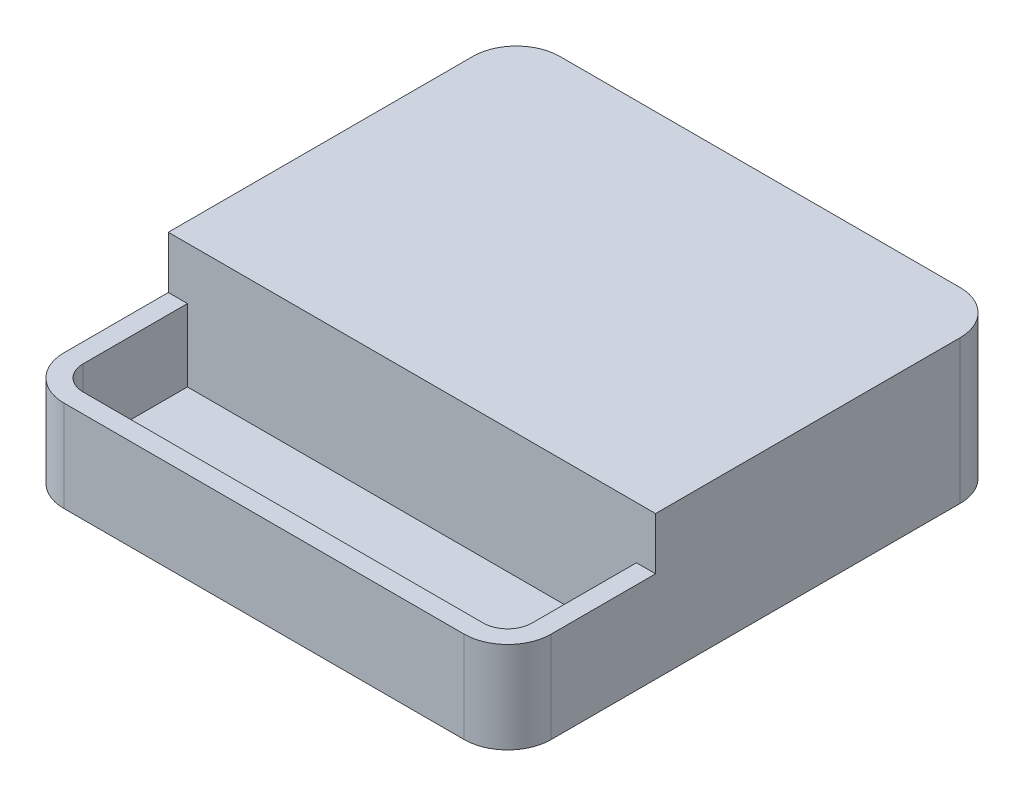
from build123d import *

# Parameters (mm, degrees)
EXTRUDE_1_DEPTH     = 16.5
SKETCH_2_W          = 56
SKETCH_2_H          = 17
CUT_EXTRUDE_1_DEPTH = 6
CUT_EXTRUDE_2_DEPTH = 8.3
SKETCH_4_R          = 7
SKETCH_4_R_2        = 0.5
EXTRUDE_2_DEPTH     = 1
SKETCH_5_R          = 4
EXTRUDE_3_DEPTH     = 4.5
SKETCH_6_R          = 2.8
EXTRUDE_4_DEPTH     = 4
SKETCH_7_R          = 1.875
EXTRUDE_5_DEPTH     = 3.5


with BuildPart() as part:
    # 草图1 → 凸台-拉伸1 (new body)
    with BuildSketch(Plane(origin=(0, 0, 0), x_dir=(1, 0, 0), z_dir=(0, 1, 0))):
        with BuildLine():
            Line((-23, 28.5), (23, 28.5))
            ThreePointArc((23, 28.5), (26.535533906, 27.035533906), (28, 23.5))
            Line((28, 23.5), (28, -23.5))
            ThreePointArc((28, -23.5), (26.535533906, -27.035533906), (23, -28.5))
            Line((23, -28.5), (-23, -28.5))
            ThreePointArc((-23, -28.5), (-26.535533906, -27.035533906), (-28, -23.5))
            Line((-28, -23.5), (-28, 23.5))
            ThreePointArc((-28, 23.5), (-26.535533906, 27.035533906), (-23, 28.5))
        make_face()
    extrude(amount=EXTRUDE_1_DEPTH)

    # 草图2 → 切除-拉伸1 (cut)
    with BuildSketch(Plane(origin=(0, 16.5, 0), x_dir=(1, 0, 0), z_dir=(0, 1, 0))):
        with Locations((0, -20)):
            Rectangle(SKETCH_2_W, SKETCH_2_H)
    extrude(amount=-CUT_EXTRUDE_1_DEPTH, mode=Mode.SUBTRACT)

    # 草图3 → 切除-拉伸2 (cut)
    with BuildSketch(Plane(origin=(0, 10.5, 0), x_dir=(1, 0, 0), z_dir=(0, 1, 0))):
        with BuildLine():
            Line((-25.8, -11.5), (25.8, -11.5))
            Line((25.8, -11.5), (25.8, -23.5))
            ThreePointArc((25.8, -23.5), (24.979898987, -25.479898987), (23, -26.3))
            Line((23, -26.3), (-23, -26.3))
            ThreePointArc((-23, -26.3), (-24.979898987, -25.479898987), (-25.8, -23.5))
            Line((-25.8, -23.5), (-25.8, -11.5))
        make_face()
    extrude(amount=-CUT_EXTRUDE_2_DEPTH, mode=Mode.SUBTRACT)

    # 草图4 → 凸台-拉伸2 (add)
    with BuildSketch(Plane.XZ):
        Circle(SKETCH_4_R)
        with Locations((-21, 23.5)):
            Circle(SKETCH_4_R_2)
        with Locations((21, 23.5)):
            Circle(SKETCH_4_R_2)
        with Locations((-21, -23.5)):
            Circle(SKETCH_4_R_2)
        with Locations((21, -23.5)):
            Circle(SKETCH_4_R_2)
    extrude(amount=EXTRUDE_2_DEPTH)

    # 草图5 → 凸台-拉伸3 (add)
    with BuildSketch(Plane.XZ.offset(1)):
        Circle(SKETCH_5_R)
    extrude(amount=EXTRUDE_3_DEPTH)

    # 草图6 → 凸台-拉伸4 (add)
    with BuildSketch(Plane.XZ.offset(5.5)):
        Circle(SKETCH_6_R)
    extrude(amount=EXTRUDE_4_DEPTH)

    # 草图7 → 凸台-拉伸5 (add)
    with BuildSketch(Plane.XZ.offset(9.5)):
        Circle(SKETCH_7_R)
    extrude(amount=EXTRUDE_5_DEPTH)


solid = part.part
